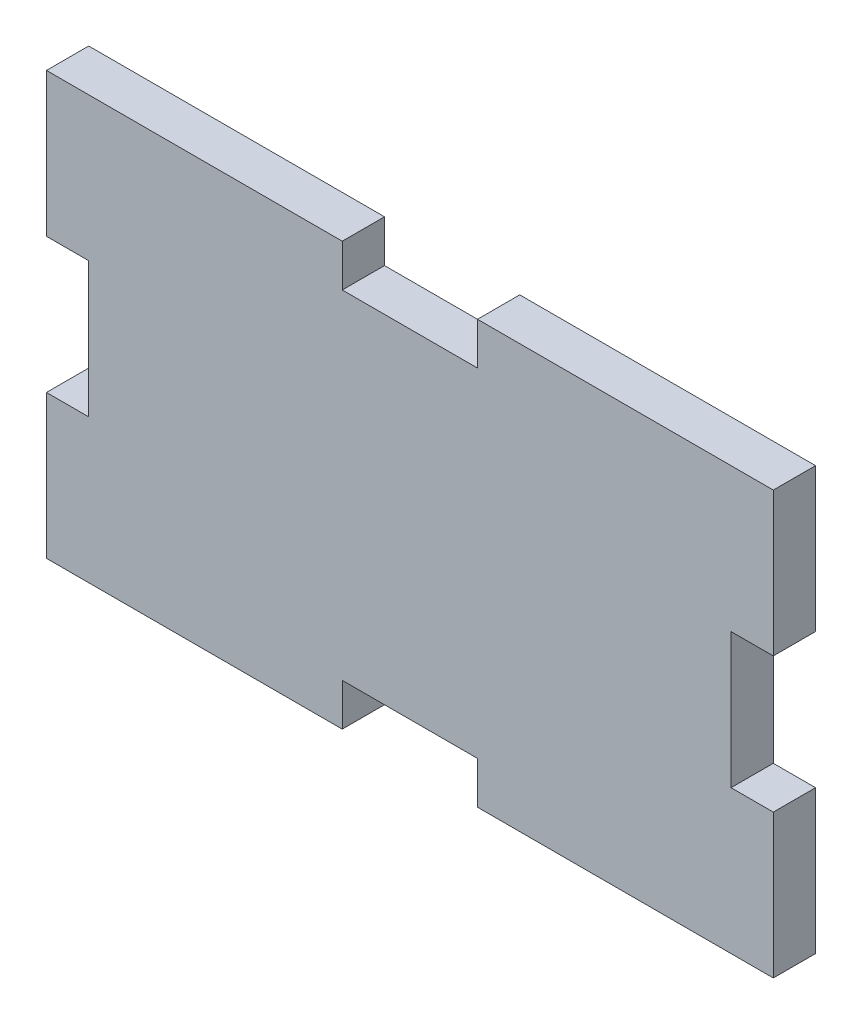
from build123d import *

# Parameters (mm, degrees)
BOSS_EXTRUDE1_DEPTH = 5


with BuildPart() as part:
    # Sketch1 → Boss-Extrude1 (new body)
    with BuildSketch(Plane.XY):
        Polygon((-43, 25), (-8, 25), (-8, 20), (8, 20), (8, 25), (43, 25), (43, 8), (38, 8), (38, -8), (43, -8), (43, -25), (8, -25), (8, -20), (-8, -20), (-8, -25), (-43, -25), (-43, -8), (-38, -8), (-38, 8), (-43, 8), align=None)
    extrude(amount=BOSS_EXTRUDE1_DEPTH)


solid = part.part
